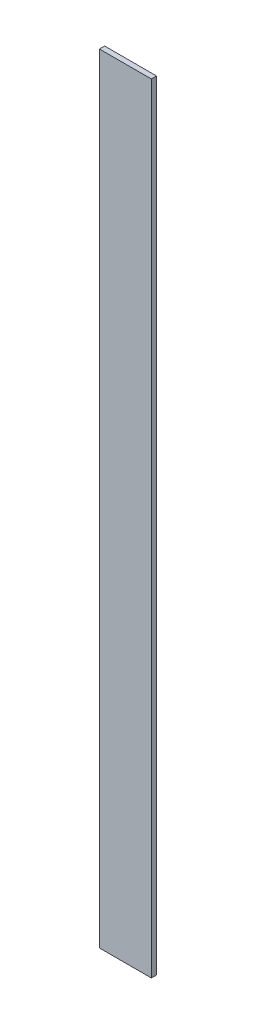
from build123d import *

# Parameters (mm, degrees)
ESBO_O1_W                = 200
ESBO_O1_H                = 20
RESSALTO_EXTRUS_O1_DEPTH = 3000


with BuildPart() as part:
    # Esboço1 → Ressalto-extrusão1 (new body)
    with BuildSketch(Plane(origin=(0, 0, 0), x_dir=(1, 0, 0), z_dir=(0, 1, 0))):
        with Locations((-1056.483688544, 794.687242443)):
            Rectangle(ESBO_O1_W, ESBO_O1_H)
    extrude(amount=RESSALTO_EXTRUS_O1_DEPTH)


solid = part.part
